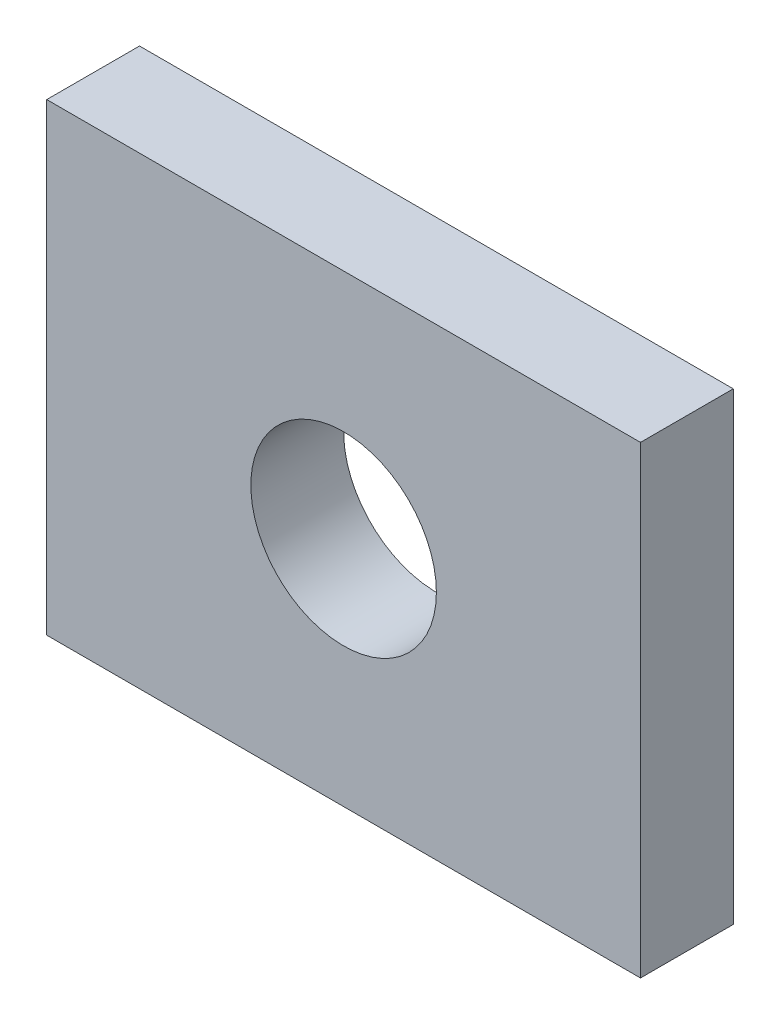
from build123d import *

# Parameters (mm, degrees)
CROQUIS1_W              = 32
CROQUIS1_H              = 25
CROQUIS1_R              = 5
SALIENTE_EXTRUIR1_DEPTH = 5


with BuildPart() as part:
    # Croquis1 → Saliente-Extruir1 (new body)
    with BuildSketch(Plane.XY):
        Rectangle(CROQUIS1_W, CROQUIS1_H)
        Circle(CROQUIS1_R, mode=Mode.SUBTRACT)
    extrude(amount=SALIENTE_EXTRUIR1_DEPTH)


solid = part.part
